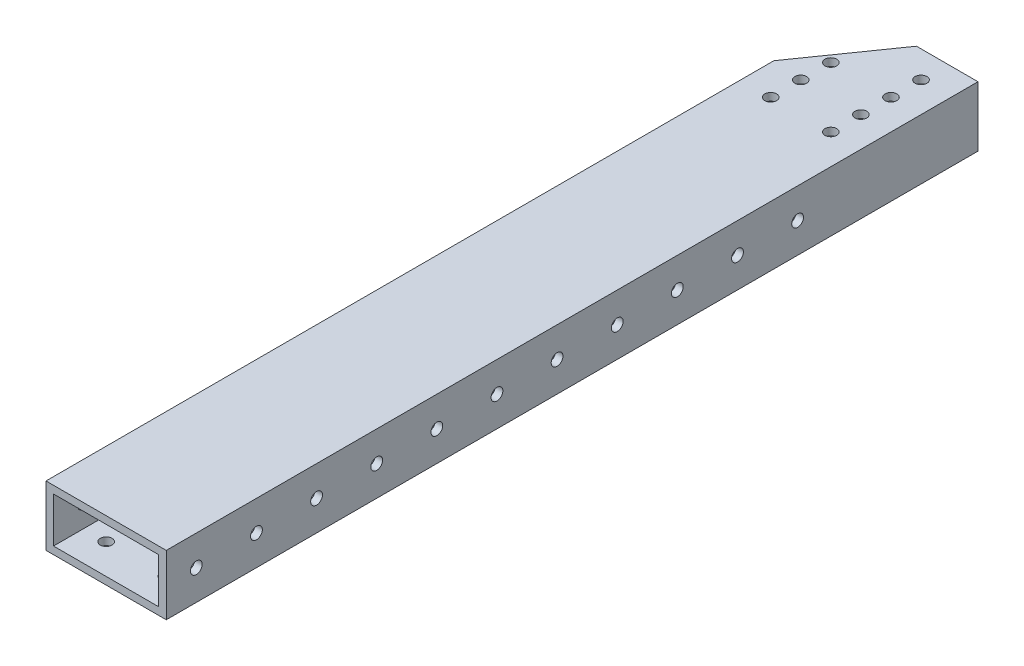
from build123d import *

# Parameters (mm, degrees)
SKETCH1_W           = 50.8
SKETCH1_H           = 342.9
BOSS_EXTRUDE1_DEPTH = 25.4
SHELL1_T            = -3.175
SKETCH2_R           = 2.4892
CUT_EXTRUDE1_DEPTH  = 51.8
SKETCH3_R           = 2.4892
CUT_EXTRUDE2_DEPTH  = 26.4
CUT_EXTRUDE3_REACH  = 27.4
SKETCH4_R           = 2.4892
SKETCH6_R           = 2.4892
CUT_EXTRUDE5_DEPTH  = 26.4


with BuildPart() as part:
    # Sketch1 → Boss-Extrude1 (new body)
    with BuildSketch(Plane(origin=(0, 0, 0), x_dir=(1, 0, 0), z_dir=(0, 1, 0))):
        with Locations((25.4, 171.45)):
            Rectangle(SKETCH1_W, SKETCH1_H)
    extrude(amount=BOSS_EXTRUDE1_DEPTH)

    # Shell1
    shell1_openings = [part.faces().sort_by_distance(p)[0] for p in [
        (25.4, 12.7, -342.9),
        (25.4, 12.7, 0),
    ]]
    offset(amount=SHELL1_T, openings=shell1_openings, kind=Kind.INTERSECTION)

    # Sketch2 → Cut-Extrude1 (cut, through all)
    with BuildSketch(Plane.ZY):
        with Locations((-12.7, 12.7)):
            Circle(SKETCH2_R)
        with Locations((-38.1, 12.7)):
            Circle(SKETCH2_R)
        with Locations((-63.5, 12.7)):
            Circle(SKETCH2_R)
        with Locations((-88.9, 12.7)):
            Circle(SKETCH2_R)
        with Locations((-114.3, 12.7)):
            Circle(SKETCH2_R)
        with Locations((-139.7, 12.7)):
            Circle(SKETCH2_R)
        with Locations((-165.1, 12.7)):
            Circle(SKETCH2_R)
        with Locations((-190.5, 12.7)):
            Circle(SKETCH2_R)
        with Locations((-215.9, 12.7)):
            Circle(SKETCH2_R)
        with Locations((-241.3, 12.7)):
            Circle(SKETCH2_R)
        with Locations((-266.7, 12.7)):
            Circle(SKETCH2_R)
    extrude(amount=-CUT_EXTRUDE1_DEPTH, mode=Mode.SUBTRACT)

    # Sketch3 → Cut-Extrude2 (cut, through all)
    with BuildSketch(Plane(origin=(0, 25.4, 0), x_dir=(1, 0, 0), z_dir=(0, 1, 0))):
        with Locations((12.7, 293.424634479)):
            Circle(SKETCH3_R)
        with Locations((38.1, 293.424634479)):
            Circle(SKETCH3_R)
        with Locations((38.1, 306.124634479)):
            Circle(SKETCH3_R)
        with Locations((12.7, 306.124634479)):
            Circle(SKETCH3_R)
        with Locations((12.7, 318.824634479)):
            Circle(SKETCH3_R)
        with Locations((38.1, 318.824634479)):
            Circle(SKETCH3_R)
        with Locations((38.1, 331.524634479)):
            Circle(SKETCH3_R)
        with Locations((12.7, 331.524634479)):
            Circle(SKETCH3_R)
    extrude(amount=-CUT_EXTRUDE2_DEPTH, mode=Mode.SUBTRACT)

    # Sketch4 → Cut-Extrude3 (cut, up to next)
    with BuildSketch(Plane.XZ, mode=Mode.PRIVATE) as cut_extrude3_sk1:
        with Locations((38.1, -12.7)):
            Circle(SKETCH4_R)
    cut_extrude3_tool1 = extrude(cut_extrude3_sk1.sketch, amount=-CUT_EXTRUDE3_REACH, mode=Mode.PRIVATE) & part.part
    add(cut_extrude3_tool1.solids().sort_by_distance((38.1, 0, -12.7))[0], mode=Mode.SUBTRACT)
    # Sketch4 → Cut-Extrude3 (cut, up to next)
    with BuildSketch(Plane.XZ, mode=Mode.PRIVATE) as cut_extrude3_sk2:
        with Locations((12.7, -12.7)):
            Circle(SKETCH4_R)
    cut_extrude3_tool2 = extrude(cut_extrude3_sk2.sketch, amount=-CUT_EXTRUDE3_REACH, mode=Mode.PRIVATE) & part.part
    add(cut_extrude3_tool2.solids().sort_by_distance((12.7, 0, -12.7))[0], mode=Mode.SUBTRACT)
    # Sketch4 → Cut-Extrude3 (cut, up to next)
    with BuildSketch(Plane.XZ, mode=Mode.PRIVATE) as cut_extrude3_sk3:
        with Locations((12.7, -25.4)):
            Circle(SKETCH4_R)
    cut_extrude3_tool3 = extrude(cut_extrude3_sk3.sketch, amount=-CUT_EXTRUDE3_REACH, mode=Mode.PRIVATE) & part.part
    add(cut_extrude3_tool3.solids().sort_by_distance((12.7, 0, -25.4))[0], mode=Mode.SUBTRACT)
    # Sketch4 → Cut-Extrude3 (cut, up to next)
    with BuildSketch(Plane.XZ, mode=Mode.PRIVATE) as cut_extrude3_sk4:
        with Locations((38.1, -25.4)):
            Circle(SKETCH4_R)
    cut_extrude3_tool4 = extrude(cut_extrude3_sk4.sketch, amount=-CUT_EXTRUDE3_REACH, mode=Mode.PRIVATE) & part.part
    add(cut_extrude3_tool4.solids().sort_by_distance((38.1, 0, -25.4))[0], mode=Mode.SUBTRACT)
    # Sketch4 → Cut-Extrude3 (cut, up to next)
    with BuildSketch(Plane.XZ, mode=Mode.PRIVATE) as cut_extrude3_sk5:
        with Locations((38.1, -38.1)):
            Circle(SKETCH4_R)
    cut_extrude3_tool5 = extrude(cut_extrude3_sk5.sketch, amount=-CUT_EXTRUDE3_REACH, mode=Mode.PRIVATE) & part.part
    add(cut_extrude3_tool5.solids().sort_by_distance((38.1, 0, -38.1))[0], mode=Mode.SUBTRACT)
    # Sketch4 → Cut-Extrude3 (cut, up to next)
    with BuildSketch(Plane.XZ, mode=Mode.PRIVATE) as cut_extrude3_sk6:
        with Locations((12.7, -38.1)):
            Circle(SKETCH4_R)
    cut_extrude3_tool6 = extrude(cut_extrude3_sk6.sketch, amount=-CUT_EXTRUDE3_REACH, mode=Mode.PRIVATE) & part.part
    add(cut_extrude3_tool6.solids().sort_by_distance((12.7, 0, -38.1))[0], mode=Mode.SUBTRACT)
    # Sketch4 → Cut-Extrude3 (cut, up to next)
    with BuildSketch(Plane.XZ, mode=Mode.PRIVATE) as cut_extrude3_sk7:
        with Locations((12.7, -50.8)):
            Circle(SKETCH4_R)
    cut_extrude3_tool7 = extrude(cut_extrude3_sk7.sketch, amount=-CUT_EXTRUDE3_REACH, mode=Mode.PRIVATE) & part.part
    add(cut_extrude3_tool7.solids().sort_by_distance((12.7, 0, -50.8))[0], mode=Mode.SUBTRACT)
    # Sketch4 → Cut-Extrude3 (cut, up to next)
    with BuildSketch(Plane.XZ, mode=Mode.PRIVATE) as cut_extrude3_sk8:
        with Locations((38.1, -50.8)):
            Circle(SKETCH4_R)
    cut_extrude3_tool8 = extrude(cut_extrude3_sk8.sketch, amount=-CUT_EXTRUDE3_REACH, mode=Mode.PRIVATE) & part.part
    add(cut_extrude3_tool8.solids().sort_by_distance((38.1, 0, -50.8))[0], mode=Mode.SUBTRACT)
    # Sketch4 → Cut-Extrude3 (cut, up to next)
    with BuildSketch(Plane.XZ, mode=Mode.PRIVATE) as cut_extrude3_sk9:
        with Locations((38.1, -63.5)):
            Circle(SKETCH4_R)
    cut_extrude3_tool9 = extrude(cut_extrude3_sk9.sketch, amount=-CUT_EXTRUDE3_REACH, mode=Mode.PRIVATE) & part.part
    add(cut_extrude3_tool9.solids().sort_by_distance((38.1, 0, -63.5))[0], mode=Mode.SUBTRACT)
    # Sketch4 → Cut-Extrude3 (cut, up to next)
    with BuildSketch(Plane.XZ, mode=Mode.PRIVATE) as cut_extrude3_sk10:
        with Locations((12.7, -63.5)):
            Circle(SKETCH4_R)
    cut_extrude3_tool10 = extrude(cut_extrude3_sk10.sketch, amount=-CUT_EXTRUDE3_REACH, mode=Mode.PRIVATE) & part.part
    add(cut_extrude3_tool10.solids().sort_by_distance((12.7, 0, -63.5))[0], mode=Mode.SUBTRACT)

    # Sketch6 → Cut-Extrude5 (cut, through all)
    with BuildSketch(Plane.XZ):
        Polygon((0, -307.473161113), (0, -342.9), (24.806139644, -342.9), align=None)
        with Locations((12.7, -331.524634479)):
            Circle(SKETCH6_R, mode=Mode.SUBTRACT)
    extrude(amount=-CUT_EXTRUDE5_DEPTH, mode=Mode.SUBTRACT)


solid = part.part
